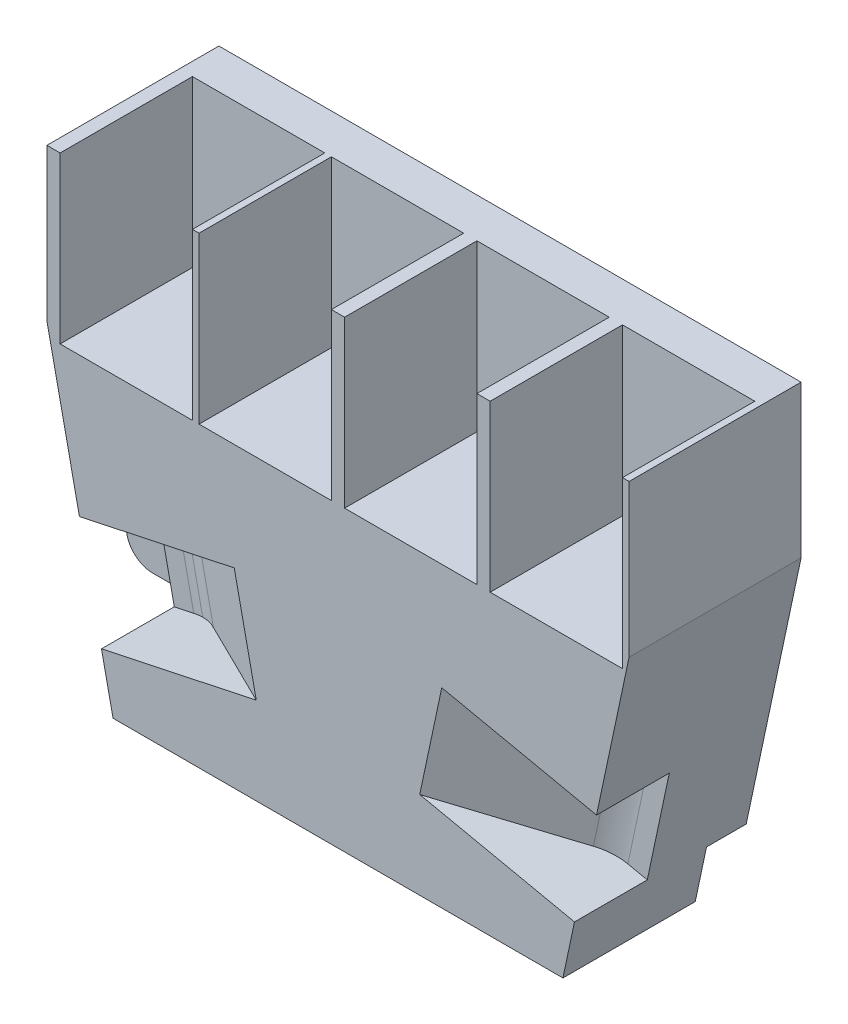
from build123d import *

# Parameters (mm, degrees)
EXTRUDE_1_DEPTH      = 26
SKETCH_3_W           = 40
SKETCH_3_H           = 36
CUT_EXTRUDE_4_DEPTH  = 20
SKETCH_4_W           = 20
SKETCH_4_H           = 20
CUT_EXTRUDE_5_DEPTH  = 25
CUT_EXTRUDE_3_DEPTH  = 8
CUT_EXTRUDE_6_DEPTH  = 8
CUT_EXTRUDE_7_DEPTH  = 16
CUT_EXTRUDE_8_DEPTH  = 16
CUT_EXTRUDE_10_DEPTH = 6
EXTRUDE_3_DEPTH      = 12
CUT_EXTRUDE_11_DEPTH = 8


with BuildPart() as part:
    # 草图1 → 凸台-拉伸1 (new body)
    with BuildSketch(Plane.XY):
        Polygon((-34, -24), (34, -24), (44, 23), (44, 46), (-44, 46), (-44, 23), align=None)
    extrude(amount=EXTRUDE_1_DEPTH)

    # 草图3 → 切除-拉伸4 (cut)
    with BuildSketch(Plane(origin=(0, 0, 0), x_dir=(-1, 0, 0), z_dir=(0, 0, -1))):
        with Locations((0, -6)):
            Rectangle(SKETCH_3_W, SKETCH_3_H)
    extrude(amount=-CUT_EXTRUDE_4_DEPTH, mode=Mode.SUBTRACT)

    # 草图4 → 切除-拉伸5 (cut)
    with BuildSketch(Plane(origin=(0, 46, 0), x_dir=(1, 0, 0), z_dir=(0, 1, 0))):
        with Locations((33, -16)):
            Rectangle(SKETCH_4_W, SKETCH_4_H)
        with Locations((11, -16)):
            Rectangle(SKETCH_4_W, SKETCH_4_H)
        with Locations((-11, -16)):
            Rectangle(SKETCH_4_W, SKETCH_4_H)
        with Locations((-32, -16)):
            Rectangle(SKETCH_4_W, SKETCH_4_H)
    extrude(amount=-CUT_EXTRUDE_5_DEPTH, mode=Mode.SUBTRACT)

    # Sketch 3D_5 → 切除-拉伸3 (cut, symmetric)
    with BuildSketch(Plane(origin=(-26.633413551, -5.666683734, 23.004025099), x_dir=(-0.691625335103945, -0.14715432661786076, 0.7071067811865475), z_dir=(-0.2081076444648591, 0.9781059289848354, 0))):
        with BuildLine():
            Line((0, 0), (5.656854249, 5.656854249))
            Line((5.656854249, 5.656854249), (11.313708499, 0))
            ThreePointArc((11.313708499, 0), (5.656854249, -13.656854249), (0, 0))
        make_face()
    extrude(amount=CUT_EXTRUDE_3_DEPTH, both=True, mode=Mode.SUBTRACT)

    # Sketch 3D_6 → 切除-拉伸6 (cut, symmetric)
    with BuildSketch(Plane(origin=(34.478414998, -7.335832978, 14.99907516), x_dir=(0.5895982688198705, -0.12544644017993214, 0.7978954016979886), z_dir=(-0.20810764446495697, -0.9781059289848145, -6.6559639472978385e-12))):
        with BuildLine():
            Line((0, 0), (6.376045072, -8.439700449))
            Line((6.376045072, -8.439700449), (17.547318622, 0))
            Line((17.547318622, 0), (11.17127355, 8.439700449))
            Line((11.17127355, 8.439700449), (6.348906145, 14.822863662))
            Line((6.348906145, 14.822863662), (1.560795809, 11.205530619))
            ThreePointArc((1.560795809, 11.205530619), (-1.540343474, 5.926016705), (0, 0))
        make_face()
    extrude(amount=CUT_EXTRUDE_6_DEPTH, both=True, mode=Mode.SUBTRACT)

    # 草图7 → 切除-拉伸7 (cut)
    with BuildSketch(Plane(origin=(-1.664861156, 7.824847432, 0), x_dir=(0.9781059289848355, 0.2081076444648587, 0), z_dir=(0.2081076444648587, -0.9781059289848355, 0))):
        with BuildLine():
            Line((-24.556702047, 20), (-31.200844281, 16.10051891))
            ThreePointArc((-31.200844281, 16.10051891), (-33.152072653, 15.280030806), (-35.250185053, 15))
            Line((-35.250185053, 15), (-43.250185053, 15))
            Line((-43.250185053, 15), (-43.250185053, 23))
            ThreePointArc((-43.250185053, 23), (-40.3181561, 29.189965223), (-33.671267687, 30.842641134))
            Line((-33.671267687, 30.842641134), (-10.087245225, 28.492198282))
            Line((-10.087245225, 28.492198282), (-24.556702047, 20))
        make_face()
    extrude(amount=CUT_EXTRUDE_7_DEPTH, mode=Mode.SUBTRACT)

    # 草图11 → 切除-拉伸8 (cut)
    with BuildSketch(Plane(origin=(-1.664861156, -7.824847432, 0), x_dir=(0.9781059289845859, -0.2081076444660318, -1.1269708570671002e-12), z_dir=(0.20810764446603178, 0.9781059289845858, 5.296763028184159e-12))):
        with BuildLine():
            Line((31.200844283, -16.100518909), (14.333584528, -26))
            Line((14.333584528, -26), (32.666556858, -30.571318601))
            ThreePointArc((32.666556858, -30.571318601), (42.196349228, -26.968728166), (40.460809076, -16.92962956))
            Line((40.460809076, -16.92962956), (38.250185053, -14.99907516))
            Line((38.250185053, -14.99907516), (35.250185053, -15))
            ThreePointArc((35.250185053, -15), (33.152072655, -15.280030806), (31.200844283, -16.100518909))
        make_face()
    extrude(amount=CUT_EXTRUDE_8_DEPTH, mode=Mode.SUBTRACT)

    # 草图12 → 切除-拉伸10 (cut)
    with BuildSketch(Plane(origin=(0, 0, 0), x_dir=(-1, 0, 0), z_dir=(0, 0, -1))):
        with BuildLine():
            Line((-34, -24), (-26, -24))
            Line((-26, -24), (-26, -20))
            ThreePointArc((-26, -20), (-27.171572875, -17.171572875), (-30, -16))
            Line((-30, -16), (-34, -16))
            Line((-34, -16), (-39.007185212, -16))
            Line((-39.007185212, -16), (-39.007185212, -24))
            Line((-39.007185212, -24), (-34, -24))
        make_face()
    extrude(amount=-CUT_EXTRUDE_10_DEPTH, mode=Mode.SUBTRACT)

    # 草图13 → 凸台-拉伸3 (add)
    with BuildSketch(Plane(origin=(0, 0, 0), x_dir=(-1, 0, 0), z_dir=(0, 0, -1))):
        with BuildLine():
            Line((34, -16), (42, -16))
            ThreePointArc((42, -16), (46, -12), (42, -8))
            Line((42, -8), (38, -8))
            Line((38, -8), (34, -8))
            Line((34, -8), (34, -16))
        make_face()
    extrude(amount=-EXTRUDE_3_DEPTH)

    # 草图14 → 切除-拉伸11 (cut)
    with BuildSketch(Plane(origin=(0, 0, 0), x_dir=(-1, 0, 0), z_dir=(0, 0, -1))):
        Polygon((37.404255319, -8), (51.058505752, -8), (50.951803073, -15.80656107), (42, -16), (35.70212766, -16), align=None)
    extrude(amount=-CUT_EXTRUDE_11_DEPTH, mode=Mode.SUBTRACT)


solid = part.part
